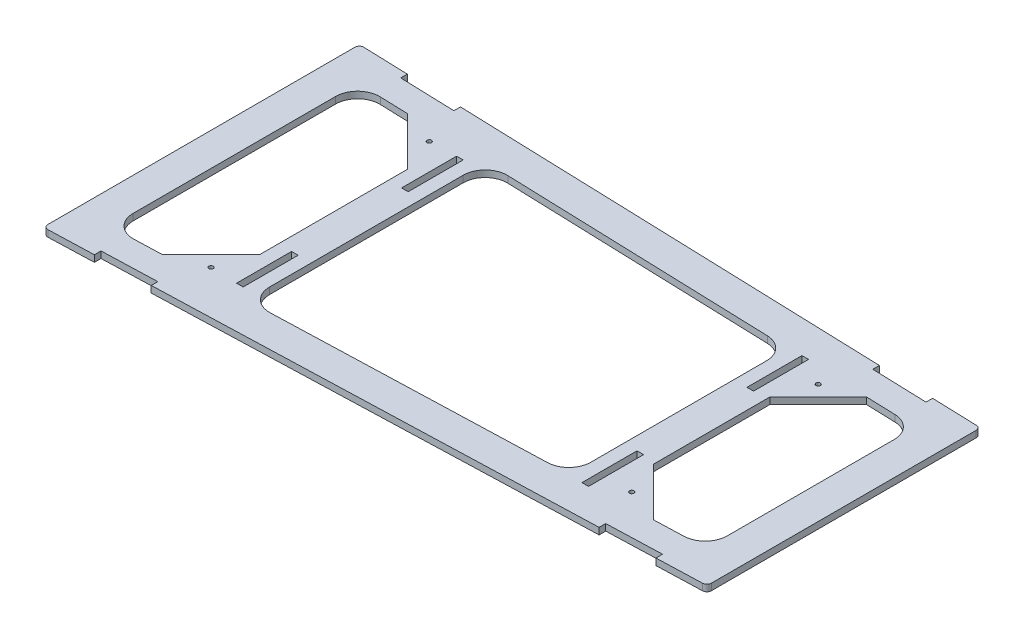
from build123d import *

# Parameters (mm, degrees)
BOSS_EXTRUDE1_DEPTH = 3
FILLET1_R           = 2
FILLET2_R           = 10
SKETCH2_W           = 3
SKETCH2_H           = 25
CUT_EXTRUDE1_DEPTH  = 10
SKETCH3_R           = 1
BOSS_EXTRUDE2_DEPTH = 3


with BuildPart() as part:
    # Sketch1 → Boss-Extrude1 (new body)
    with BuildSketch(Plane(origin=(0, 0, 0), x_dir=(1, 0, 0), z_dir=(0, 1, 0))):
        Polygon((0, 71.865), (0, -71.865), (292, -62.13), (292, 62.13), align=None)
        Polygon((15, 56.356580511), (60, 54.856323662), (60, -54.856323662), (15, -56.356580511), align=None, mode=Mode.SUBTRACT)
        Polygon((277, 47.621751744), (277, -47.621751744), (232, -49.122008593), (232, 49.122008593), align=None, mode=Mode.SUBTRACT)
        Polygon((75, 54.356238045), (75, -54.356238045), (217, -49.62209421), (217, 49.62209421), align=None, mode=Mode.SUBTRACT)
    extrude(amount=BOSS_EXTRUDE1_DEPTH)

    # Fillet1
    fillet1_edges = [part.edges().sort_by_distance(p)[0] for p in [
        (0, 1.5, 71.865),
        (0, 1.5, -71.865),
        (292, 1.5, -62.13),
        (292, 1.5, 62.13),
    ]]
    fillet(fillet1_edges, radius=FILLET1_R)

    # Fillet2
    fillet2_edges = [part.edges().sort_by_distance(p)[0] for p in [
        (217, 1.5, -49.62209421),
        (75, 1.5, -54.356238045),
        (75, 1.5, 54.356238045),
        (217, 1.5, 49.62209421),
        (15, 1.5, -56.356580511),
        (15, 1.5, 56.356580511),
        (60, 1.5, 54.856323662),
        (60, 1.5, -54.856323662),
        (277, 1.5, -47.621751744),
        (232, 1.5, -49.122008593),
        (232, 1.5, 49.122008593),
        (277, 1.5, 47.621751744),
    ]]
    fillet(fillet2_edges, radius=FILLET2_R)

    # Sketch2 → Cut-Extrude1 (cut)
    with BuildSketch(Plane(origin=(0, 3, 0), x_dir=(1, 0, 0), z_dir=(0, 1, 0))):
        Polygon((47.5, 70.281395548), (22.5, 71.114871575), (22.5, 68.114871575), (47.5, 67.281395548), align=None)
        Polygon((269.5, 62.880128425), (244.5, 63.713604452), (244.5, 60.713604452), (269.5, 59.880128425), align=None)
        with Locations((67.5, 37.5)):
            Rectangle(SKETCH2_W, SKETCH2_H)
        with Locations((224.5, 37.5)):
            Rectangle(SKETCH2_W, SKETCH2_H)
    cut_extrude1 = extrude(amount=-CUT_EXTRUDE1_DEPTH, mode=Mode.SUBTRACT)

    # Mirror1: Cut-Extrude1 across plane
    add(cut_extrude1.mirror(Plane.XY), mode=Mode.SUBTRACT)

    # Sketch3 → Boss-Extrude2 (add)
    with BuildSketch(Plane(origin=(0, 3, 0), x_dir=(1, 0, 0), z_dir=(0, 1, 0))):
        Polygon((38, 55.589782566), (60, 33.589782566), (61.509816897, 56.691838505), align=None)
        with Locations(Location((54, 49.589782566, 0), (0, 0, 270))):
            Circle(SKETCH3_R, mode=Mode.SUBTRACT)
        Polygon((232, 26.388549689), (254, 48.388549689), (229.701692371, 51.044206748), align=None)
        with Locations(Location((238, 42.388549689, 0), (0, 0, 270))):
            Circle(SKETCH3_R, mode=Mode.SUBTRACT)
        Polygon((254, -48.388549689), (229.701692371, -51.044206748), (232, -26.388549689), align=None)
        with Locations(Location((238, -42.388549689, 0), (0, 0, 90))):
            Circle(SKETCH3_R, mode=Mode.SUBTRACT)
        Polygon((60, -33.589782566), (61.509816897, -56.691838505), (38, -55.589782566), align=None)
        with Locations(Location((54, -49.589782566, 0), (0, 0, 90))):
            Circle(SKETCH3_R, mode=Mode.SUBTRACT)
    extrude(amount=-BOSS_EXTRUDE2_DEPTH)


solid = part.part
